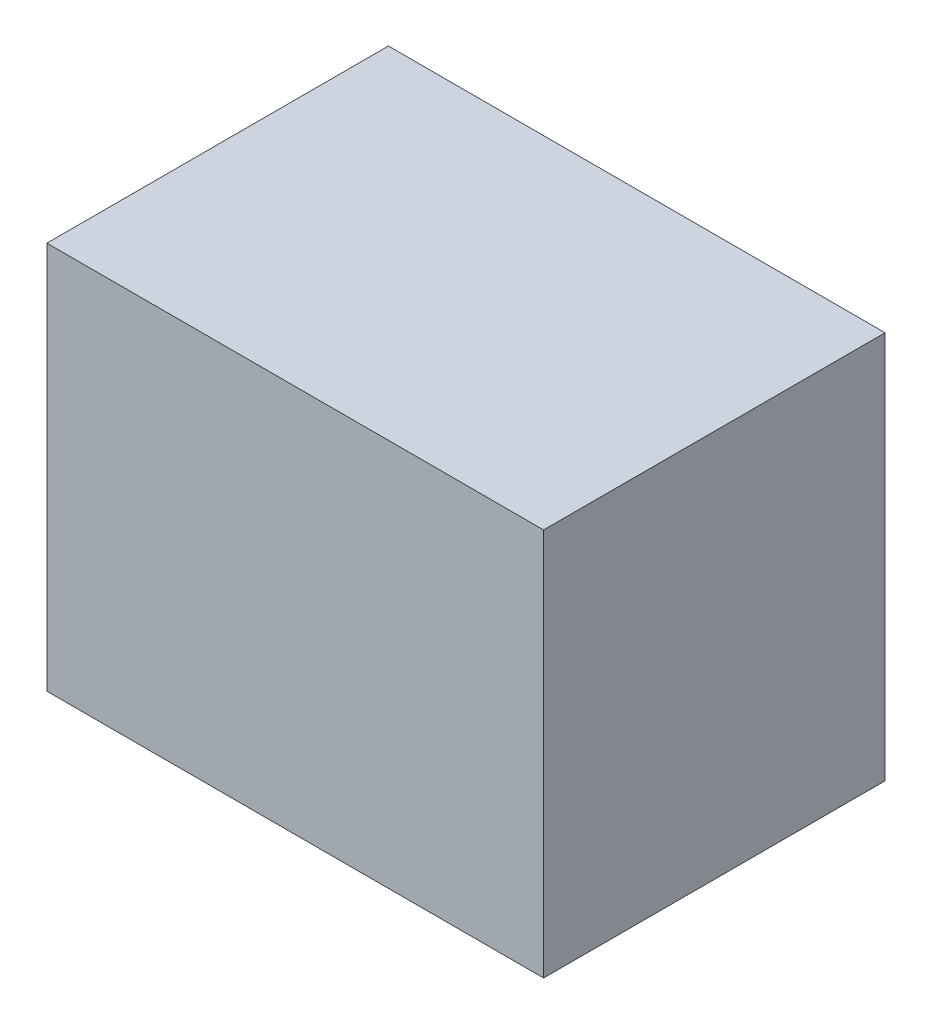
from build123d import *

# Parameters (mm, degrees)
SKETCH1_W           = 254
SKETCH1_H           = 174.625
BOSS_EXTRUDE1_DEPTH = 198.4375


with BuildPart() as part:
    # Sketch1 → Boss-Extrude1 (new body)
    with BuildSketch(Plane(origin=(0, 0, 0), x_dir=(1, 0, 0), z_dir=(0, 1, 0))):
        with Locations((127, 87.3125)):
            Rectangle(SKETCH1_W, SKETCH1_H)
    extrude(amount=BOSS_EXTRUDE1_DEPTH)


solid = part.part
